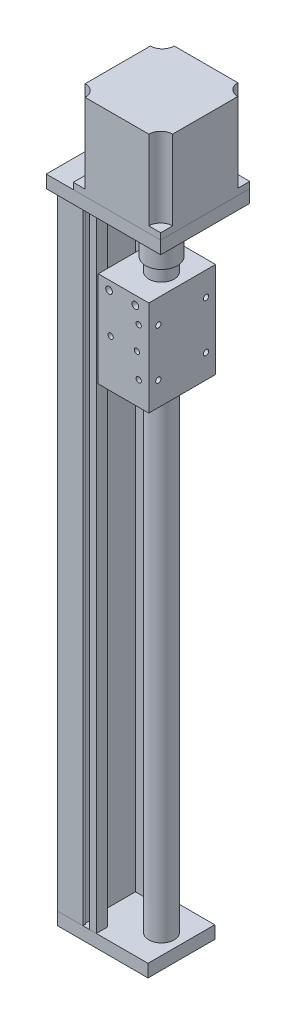
from build123d import *

# Parameters (mm, degrees)
SKETCH1_W                      = 57
SKETCH1_H                      = 42
BOSS_EXTRUDE1_DEPTH            = 8
BOSS_EXTRUDE2_DEPTH            = 397
SKETCH3_W                      = 72
SKETCH3_H                      = 56
BOSS_EXTRUDE3_DEPTH            = 8
SKETCH4_W                      = 55
SKETCH4_H                      = 56
BOSS_EXTRUDE4_DEPTH            = 54
CUT_EXTRUDE1_DEPTH             = 50
SKETCH6_R                      = 8
BOSS_EXTRUDE5_DEPTH            = 368.3
SKETCH7_W                      = 31.8
SKETCH7_H                      = 42
BOSS_EXTRUDE6_DEPTH            = 30
SKETCH8_R                      = 10
BOSS_EXTRUDE7_DEPTH            = 25
SKETCH9_R                      = 15
CUT_EXTRUDE2_DEPTH             = 5
BOSS_EXTRUDE8_REACH            = 67.7
SKETCH10_R                     = 3.175
SKETCH11_W                     = 4.3
SKETCH11_H                     = 397
CUT_EXTRUDE3_DEPTH             = 5.4
SKETCH12_W                     = 3.6
SKETCH12_H                     = 397
CUT_EXTRUDE4_DEPTH             = 2.7
SKETCH13_W                     = 4.3
SKETCH13_H                     = 397
CUT_EXTRUDE5_DEPTH             = 6.8
SKETCH14_W                     = 3.3
SKETCH14_H                     = 397
CUT_EXTRUDE6_DEPTH             = 3.4
M4X0_7_TAPPED_HOLE1_D          = 3.3
M4X0_7_TAPPED_HOLE1_DEPTH      = 10.1
M4X0_7_TAPPED_HOLE1_TIP        = 0.991420021
M4X0_7_TAPPED_HOLE2_AT_2_COUNT = 2
M4X0_7_TAPPED_HOLE2_AT_2_PITCH = 30
M4X0_7_TAPPED_HOLE2_AT_3_COUNT = 2
M4X0_7_TAPPED_HOLE2_AT_3_PITCH = 15.044018745
M4X0_7_TAPPED_HOLE2_AT_4_COUNT = 2
M4X0_7_TAPPED_HOLE2_AT_4_PITCH = 23.162955338
M5X0_8_TAPPED_HOLE1_AT_2_COUNT = 2
M5X0_8_TAPPED_HOLE1_AT_2_PITCH = 16.5


with BuildPart() as part:
    # Sketch1 → Boss-Extrude1 (new body)
    with BuildSketch(Plane(origin=(0, 0, 0), x_dir=(1, 0, 0), z_dir=(0, 1, 0))):
        with Locations((28.5, 0)):
            Rectangle(SKETCH1_W, SKETCH1_H)
    extrude(amount=BOSS_EXTRUDE1_DEPTH)

    # Sketch2 → Boss-Extrude2 (add)
    with BuildSketch(Plane(origin=(0, 8, 0), x_dir=(1, 0, 0), z_dir=(0, 1, 0))):
        Polygon((0, 21), (0, -21), (24.5, -21), (24.5, -14), (14.1, -14), (14.1, 14), (24.5, 14), (24.5, 21), align=None)
    extrude(amount=BOSS_EXTRUDE2_DEPTH)

    # Sketch3 → Boss-Extrude3 (add)
    with BuildSketch(Plane(origin=(0, 405, 0), x_dir=(1, 0, 0), z_dir=(0, 1, 0))):
        with Locations((36, 0)):
            Rectangle(SKETCH3_W, SKETCH3_H)
    extrude(amount=BOSS_EXTRUDE3_DEPTH)

    # Sketch4 → Boss-Extrude4 (add)
    with BuildSketch(Plane(origin=(0, 413, 0), x_dir=(1, 0, 0), z_dir=(0, 1, 0))):
        with Locations((44.5, 0)):
            Rectangle(SKETCH4_W, SKETCH4_H)
    extrude(amount=BOSS_EXTRUDE4_DEPTH)

    # Sketch5 → Cut-Extrude1 (cut)
    with BuildSketch(Plane(origin=(0, 467, 0), x_dir=(1, 0, 0), z_dir=(0, 1, 0))):
        with BuildLine():
            Line((17, 28), (17, 20.5))
            ThreePointArc((17, 20.5), (22.303300859, 22.696699141), (24.5, 28))
            Line((24.5, 28), (17, 28))
        make_face()
        with BuildLine():
            Line((72, 28), (64.5, 28))
            ThreePointArc((64.5, 28), (66.696699141, 22.696699141), (72, 20.5))
            Line((72, 20.5), (72, 28))
        make_face()
        with BuildLine():
            Line((72, -28), (72, -20.5))
            ThreePointArc((72, -20.5), (66.696699141, -22.696699141), (64.5, -28))
            Line((64.5, -28), (72, -28))
        make_face()
        with BuildLine():
            Line((17, -28), (24.5, -28))
            ThreePointArc((24.5, -28), (22.303300859, -22.696699141), (17, -20.5))
            Line((17, -20.5), (17, -28))
        make_face()
    extrude(amount=-CUT_EXTRUDE1_DEPTH, mode=Mode.SUBTRACT)

    # Sketch6 → Boss-Extrude5 (add)
    with BuildSketch(Plane(origin=(0, 8, 0), x_dir=(1, 0, 0), z_dir=(0, 1, 0))):
        with Locations((44.5, 0)):
            Circle(SKETCH6_R)
    extrude(amount=BOSS_EXTRUDE5_DEPTH)

    # Sketch7 → Boss-Extrude6 (add, symmetric)
    with BuildSketch(Plane(origin=(0, 338, 0), x_dir=(1, 0, 0), z_dir=(0, 1, 0))):
        with Locations((41.6, 0)):
            Rectangle(SKETCH7_W, SKETCH7_H)
    extrude(amount=BOSS_EXTRUDE6_DEPTH, both=True)

    # Sketch8 → Boss-Extrude7 (add)
    with BuildSketch(Plane(origin=(0, 376.3, 0), x_dir=(1, 0, 0), z_dir=(0, 1, 0))):
        with Locations((44.5, 0)):
            Circle(SKETCH8_R)
    extrude(amount=BOSS_EXTRUDE7_DEPTH)

    # Sketch9 → Cut-Extrude2 (cut)
    with BuildSketch(Plane.XZ.offset(-405)):
        with Locations((44.5, 0)):
            Circle(SKETCH9_R)
    extrude(amount=-CUT_EXTRUDE2_DEPTH, mode=Mode.SUBTRACT)

    # Sketch10 → Boss-Extrude8 (add, up to next)
    with BuildSketch(Plane(origin=(0, 401.3, 0), x_dir=(1, 0, 0), z_dir=(0, 1, 0)), mode=Mode.PRIVATE) as boss_extrude8_sk1:
        with Locations((44.5, 0)):
            Circle(SKETCH10_R)
    boss_extrude8_tool1 = extrude(boss_extrude8_sk1.sketch, amount=BOSS_EXTRUDE8_REACH, mode=Mode.PRIVATE) - part.part
    add(boss_extrude8_tool1.solids().sort_by_distance((44.5, 401.3, 0))[0])

    # Sketch11 → Cut-Extrude3 (cut)
    with BuildSketch(Plane(origin=(0, 0, -21), x_dir=(-1, 0, 0), z_dir=(0, 0, -1))):
        with Locations((-18.15, 206.5)):
            Rectangle(SKETCH11_W, SKETCH11_H)
    cut_extrude3 = extrude(amount=-CUT_EXTRUDE3_DEPTH, mode=Mode.SUBTRACT)

    # Sketch12 → Cut-Extrude4 (cut, symmetric)
    with BuildSketch(Plane(origin=(18.15, 0, 0), x_dir=(0, 0, -1), z_dir=(1, 0, 0))):
        with Locations((17.4, 206.5)):
            Rectangle(SKETCH12_W, SKETCH12_H)
    cut_extrude4 = extrude(amount=CUT_EXTRUDE4_DEPTH, both=True, mode=Mode.SUBTRACT)

    # Mirror1: Cut-Extrude3, Cut-Extrude4 across plane
    add(cut_extrude3.mirror(Plane.XY), mode=Mode.SUBTRACT)
    add(cut_extrude4.mirror(Plane.XY), mode=Mode.SUBTRACT)

    # Sketch13 → Cut-Extrude5 (cut)
    with BuildSketch(Plane.ZY):
        with Locations((15, 206.5)):
            Rectangle(SKETCH13_W, SKETCH13_H)
    cut_extrude5 = extrude(amount=-CUT_EXTRUDE5_DEPTH, mode=Mode.SUBTRACT)

    # Sketch14 → Cut-Extrude6 (cut, symmetric)
    with BuildSketch(Plane.XY.offset(15)):
        with Locations((3.65, 206.5)):
            Rectangle(SKETCH14_W, SKETCH14_H)
    cut_extrude6 = extrude(amount=CUT_EXTRUDE6_DEPTH, both=True, mode=Mode.SUBTRACT)

    # Mirror2: Cut-Extrude5, Cut-Extrude6 across plane
    add(cut_extrude5.mirror(Plane.XY), mode=Mode.SUBTRACT)
    add(cut_extrude6.mirror(Plane.XY), mode=Mode.SUBTRACT)

    # M4x0.7 Tapped Hole1
    with Locations(Plane(origin=(57.5, 0, 0), x_dir=(0, 0, -1), z_dir=(1, 0, 0))):
        with Locations((-15, 353), (15, 353), (15, 323), (-15, 323)):
            Hole(M4X0_7_TAPPED_HOLE1_D / 2, depth=M4X0_7_TAPPED_HOLE1_DEPTH)
            with Locations((0, 0, -(M4X0_7_TAPPED_HOLE1_DEPTH + M4X0_7_TAPPED_HOLE1_TIP / 2))):  # 118° drill point
                Cone(0, M4X0_7_TAPPED_HOLE1_D / 2, M4X0_7_TAPPED_HOLE1_TIP, mode=Mode.SUBTRACT)

    # Sketch23 → M4x0.7 Tapped Hole2 (revolve, cut)
    with BuildSketch(Plane(origin=(51.15, 323, 21), x_dir=(0, -1, 0), z_dir=(1, 0, 0))):
        Polygon((0, 0), (0, 6.991420021), (1.65, 6), (1.65, 0), align=None)
    m4x0_7_tapped_hole2 = revolve(axis=Axis((51.15, 323, 27.35), (0, 0, -1)), mode=Mode.SUBTRACT)

    # M4x0.7 Tapped Hole2 at 2: M4x0.7 Tapped Hole2 ×2
    with Locations(*[(0, i * M4X0_7_TAPPED_HOLE2_AT_2_PITCH, 0) for i in range(1, M4X0_7_TAPPED_HOLE2_AT_2_COUNT)]):
        add(m4x0_7_tapped_hole2, mode=Mode.SUBTRACT)

    # M4x0.7 Tapped Hole2 at 3: M4x0.7 Tapped Hole2 ×2
    with Locations(*[Vector(-0.07644234, 0.997074004, 0) * (i * M4X0_7_TAPPED_HOLE2_AT_3_PITCH) for i in range(1, M4X0_7_TAPPED_HOLE2_AT_3_COUNT)]):
        add(m4x0_7_tapped_hole2, mode=Mode.SUBTRACT)

    # M4x0.7 Tapped Hole2 at 4: M4x0.7 Tapped Hole2 ×2
    with Locations(*[Vector(-0.761992576, 0.647585758, 0) * (i * M4X0_7_TAPPED_HOLE2_AT_4_PITCH) for i in range(1, M4X0_7_TAPPED_HOLE2_AT_4_COUNT)]):
        add(m4x0_7_tapped_hole2, mode=Mode.SUBTRACT)

    # Sketch25 → M5x0.8 Tapped Hole1 (revolve, cut)
    with BuildSketch(Plane(origin=(32.5, 362.5, 21), x_dir=(0, -1, 0), z_dir=(1, 0, 0))):
        Polygon((0, 0), (0, 11.2618073), (2.1, 10), (2.1, 0), align=None)
    m5x0_8_tapped_hole1 = revolve(axis=Axis((32.5, 362.5, 27.35), (0, 0, -1)), mode=Mode.SUBTRACT)

    # M5x0.8 Tapped Hole1 at 2: M5x0.8 Tapped Hole1 ×2
    with Locations(*[(i * M5X0_8_TAPPED_HOLE1_AT_2_PITCH, 0, 0) for i in range(1, M5X0_8_TAPPED_HOLE1_AT_2_COUNT)]):
        add(m5x0_8_tapped_hole1, mode=Mode.SUBTRACT)

    # Mirror3: M5x0.8 Tapped Hole1, M4x0.7 Tapped Hole2 across plane
    add(m5x0_8_tapped_hole1.mirror(Plane.XY), mode=Mode.SUBTRACT)
    add(m4x0_7_tapped_hole2.mirror(Plane.XY), mode=Mode.SUBTRACT)

    # Mirror3 copy 1 sketch → Mirror3 copy 1 (revolve, cut)
    with BuildSketch(Plane(origin=(49, 362.5, -21), x_dir=(0, -1, 0), z_dir=(1, 0, 0))):
        Polygon((0, 0), (0, -11.2618073), (2.1, -10), (2.1, 0), align=None)
    revolve(axis=Axis((49, 362.5, -27.35), (0, 0, -1)), mode=Mode.SUBTRACT)

    # Mirror3 copy 2 sketch → Mirror3 copy 2 (revolve, cut)
    with BuildSketch(Plane(origin=(51.15, 353, -21), x_dir=(0, -1, 0), z_dir=(1, 0, 0))):
        Polygon((0, 0), (0, -6.991420021), (1.65, -6), (1.65, 0), align=None)
    revolve(axis=Axis((51.15, 353, -27.35), (0, 0, -1)), mode=Mode.SUBTRACT)

    # Mirror3 copy 3 sketch → Mirror3 copy 3 (revolve, cut)
    with BuildSketch(Plane(origin=(50, 338, -21), x_dir=(0, -1, 0), z_dir=(1, 0, 0))):
        Polygon((0, 0), (0, -6.991420021), (1.65, -6), (1.65, 0), align=None)
    revolve(axis=Axis((50, 338, -27.35), (0, 0, -1)), mode=Mode.SUBTRACT)

    # Mirror3 copy 4 sketch → Mirror3 copy 4 (revolve, cut)
    with BuildSketch(Plane(origin=(33.5, 338, -21), x_dir=(0, -1, 0), z_dir=(1, 0, 0))):
        Polygon((0, 0), (0, -6.991420021), (1.65, -6), (1.65, 0), align=None)
    revolve(axis=Axis((33.5, 338, -27.35), (0, 0, -1)), mode=Mode.SUBTRACT)


solid = part.part
